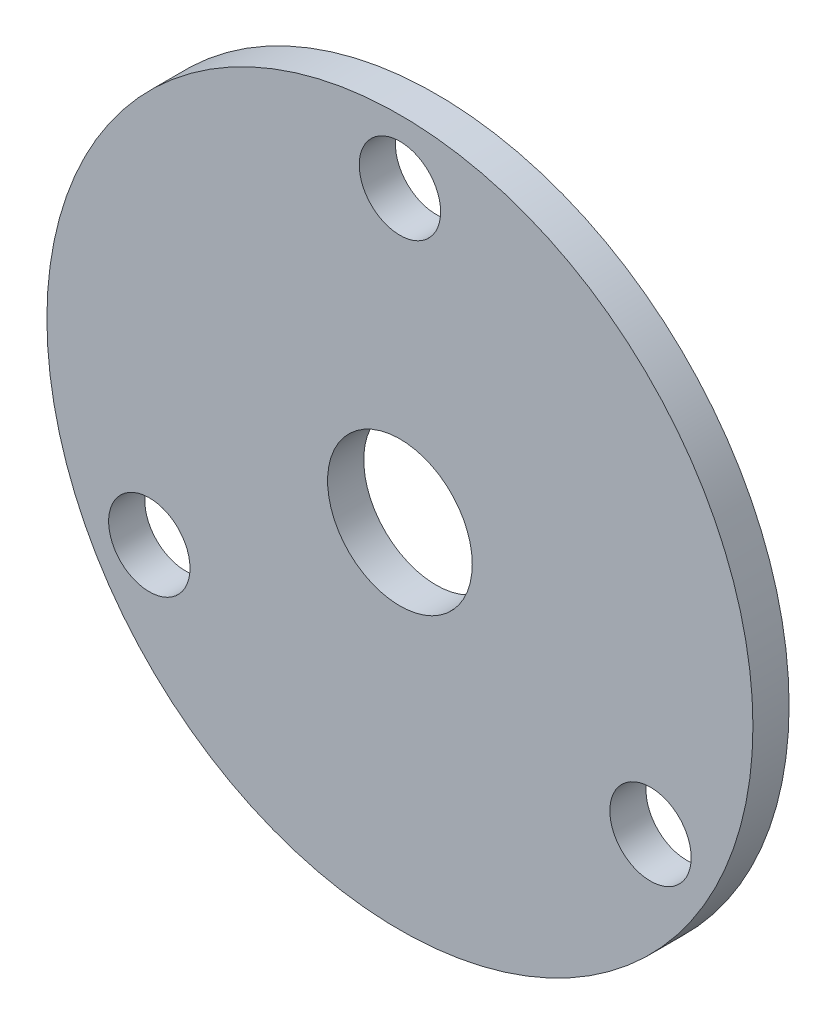
from build123d import *

# Parameters (mm, degrees)
SKETCH1_R                      = 61.976
BOSS_EXTRUDE1_DEPTH            = 6.35
F_1_1_DIAMETER_HOLE1_D         = 25.4
F_9_16_0_5625_DIAMETER_HOLE1_D = 14.2875


with BuildPart() as part:
    # Sketch1 → Boss-Extrude1 (new body)
    with BuildSketch(Plane.XY):
        Circle(SKETCH1_R)
    extrude(amount=BOSS_EXTRUDE1_DEPTH)

    # 1 (1) Diameter Hole1 (through all)
    with Locations(Plane.XY.offset(6.35)):
        with Locations((0, 0)):
            Hole(F_1_1_DIAMETER_HOLE1_D / 2)

    # 9/16 (0.5625) Diameter Hole1 (through all)
    with Locations(Plane.XY.offset(6.35)):
        with Locations((-43.994090512, -25.4), (43.994090512, -25.4), (0, 50.8)):
            Hole(F_9_16_0_5625_DIAMETER_HOLE1_D / 2)


solid = part.part
